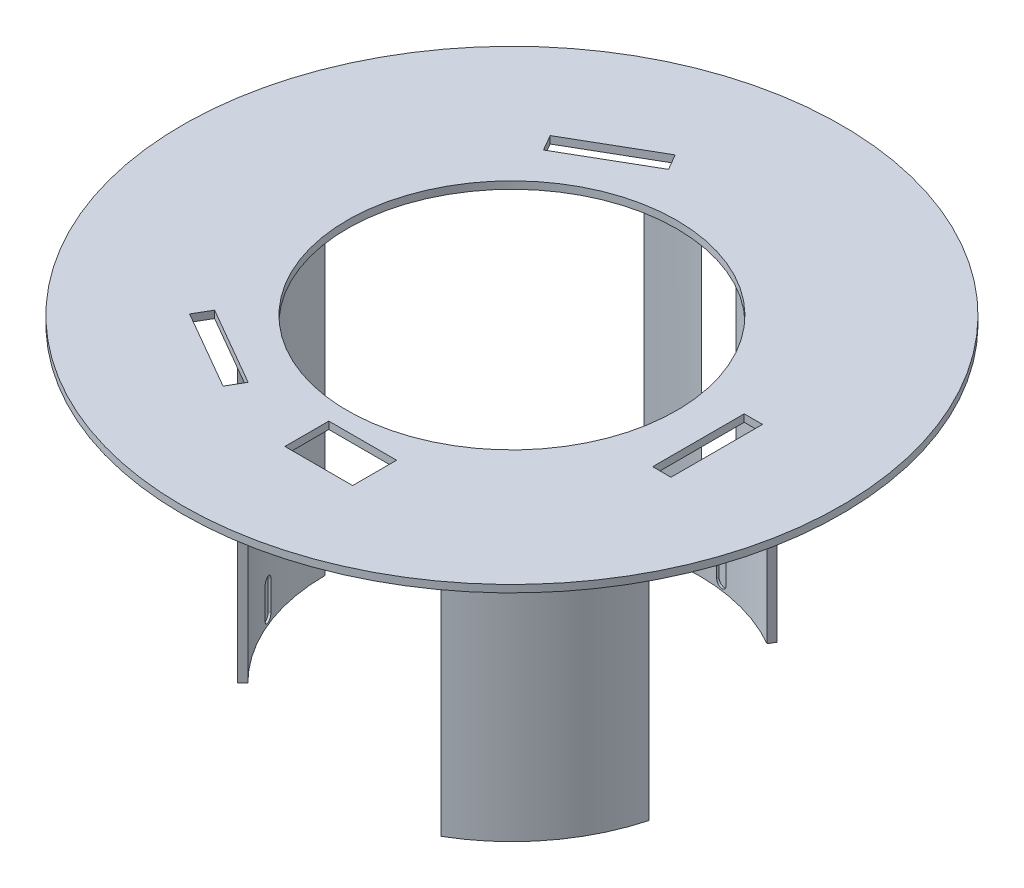
from build123d import *

# Parameters (mm, degrees)
SKETCH3_R           = 90
BOSS_EXTRUDE3_DEPTH = 2
SKETCH4_R           = 45
CUT_EXTRUDE1_DEPTH  = 2
BOSS_EXTRUDE4_DEPTH = 85
BOSS_EXTRUDE5_DEPTH = 85
CUT_EXTRUDE9_DEPTH  = 10
CIRPATTERN4_COUNT   = 3
CUT_EXTRUDE5_DEPTH  = 60
SKETCH15_W          = 5
SKETCH15_H          = 25
CUT_EXTRUDE10_DEPTH = 88.0000001
CIRPATTERN5_COUNT   = 3
SKETCH16_R          = 46
CUT_EXTRUDE11_DEPTH = 85
BOSS_EXTRUDE6_DEPTH = 2
SKETCH18_W          = 18.5
SKETCH18_H          = 12
CUT_EXTRUDE12_DEPTH = 2


with BuildPart() as part:
    # Sketch3 → Boss-Extrude3 (new body)
    with BuildSketch(Plane(origin=(0, 0, 0), x_dir=(1, 0, 0), z_dir=(0, 1, 0))):
        Circle(SKETCH3_R)
    extrude(amount=BOSS_EXTRUDE3_DEPTH)

    # Sketch4 → Cut-Extrude1 (cut)
    with BuildSketch(Plane.XZ):
        Circle(SKETCH4_R)
    extrude(amount=-CUT_EXTRUDE1_DEPTH, mode=Mode.SUBTRACT)

    # Sketch6 → Boss-Extrude4 (add)
    with BuildSketch(Plane.XZ):
        with BuildLine():
            Line((-46, 0), (-45, 0))
            ThreePointArc((-45, 0), (-41.574578963, 17.220754456), (-31.819805153, 31.819805153))
            Line((-31.819805153, 31.819805153), (-32.526911935, 32.526911935))
            ThreePointArc((-32.526911935, 32.526911935), (-42.498458496, 17.603437889), (-46, 0))
        make_face()
    boss_extrude4 = extrude(amount=BOSS_EXTRUDE4_DEPTH)

    # Sketch6_3 → Boss-Extrude5 (add)
    with BuildSketch(Plane.XZ):
        with BuildLine():
            Line((-53, 0), (-51, 0))
            ThreePointArc((-51, 0), (-47.117856158, 19.516855051), (-36.062445841, 36.062445841))
            Line((-36.062445841, 36.062445841), (-37.476659403, 37.476659403))
            ThreePointArc((-37.476659403, 37.476659403), (-48.965615223, 20.282221915), (-53, 0))
        make_face()
    boss_extrude5 = extrude(amount=BOSS_EXTRUDE5_DEPTH)

    # Sketch14 → Cut-Extrude9 (cut)
    with BuildSketch(Plane(origin=(-38.409902577, 0, 15.909902577), x_dir=(-0.382683432, 0, -0.923879533), z_dir=(0.923879533, 0, -0.382683432))):
        with BuildLine():
            Line((1.5, -75), (1.5, -83))
            ThreePointArc((1.5, -83), (0, -84.5), (-1.5, -83))
            Line((-1.5, -83), (-1.5, -75))
            ThreePointArc((-1.5, -75), (0, -73.5), (1.5, -75))
        make_face()
    cut_extrude9 = extrude(amount=-CUT_EXTRUDE9_DEPTH, mode=Mode.SUBTRACT)

    # CirPattern4: Boss-Extrude4, Boss-Extrude5, Cut-Extrude9 ×3 about axis
    cirpattern4_axis = Axis((0, 0, 0), (0, 1, 0))
    for i in range(1, CIRPATTERN4_COUNT):
        add(boss_extrude4.rotate(cirpattern4_axis, i * 360 / CIRPATTERN4_COUNT))
        add(boss_extrude5.rotate(cirpattern4_axis, i * 360 / CIRPATTERN4_COUNT))
        add(cut_extrude9.rotate(cirpattern4_axis, i * 360 / CIRPATTERN4_COUNT), mode=Mode.SUBTRACT)

    # Sketch11 → Cut-Extrude5 (cut, symmetric)
    with BuildSketch(Plane.XZ):
        Polygon((-6.747570404, -52.479477871), (11.40662685, -48.919264104), (13.715954699, -60.69495962), (-4.438242555, -64.255173387), align=None)
    extrude(amount=CUT_EXTRUDE5_DEPTH, both=True, mode=Mode.SUBTRACT)

    # Sketch15 → Cut-Extrude10 (cut, through all)
    with BuildSketch(Plane(origin=(0, 2, 0), x_dir=(1, 0, 0), z_dir=(0, 1, 0))):
        with Locations((57.5, -4.067185812)):
            Rectangle(SKETCH15_W, SKETCH15_H)
    cut_extrude10 = extrude(amount=-CUT_EXTRUDE10_DEPTH, mode=Mode.SUBTRACT)

    # CirPattern5: Cut-Extrude10 ×3 about axis
    cirpattern5_axis = Axis((0, 0, 0), (0, 1, 0))
    for i in range(1, CIRPATTERN5_COUNT):
        add(cut_extrude10.rotate(cirpattern5_axis, i * 360 / CIRPATTERN5_COUNT), mode=Mode.SUBTRACT)

    # Sketch16 → Cut-Extrude11 (cut)
    with BuildSketch(Plane.XZ.offset(85)):
        Circle(SKETCH16_R)
    extrude(amount=-CUT_EXTRUDE11_DEPTH, mode=Mode.SUBTRACT)

    # Sketch17 → Boss-Extrude6 (add)
    with BuildSketch(Plane(origin=(0, 2, 0), x_dir=(1, 0, 0), z_dir=(0, 1, 0))):
        Polygon((13.715954699, 60.69495962), (-4.438242555, 64.255173387), (-6.747570404, 52.479477871), (11.40662685, 48.919264104), align=None)
    extrude(amount=-BOSS_EXTRUDE6_DEPTH)

    # Sketch18 → Cut-Extrude12 (cut)
    with BuildSketch(Plane(origin=(0, 2, 0), x_dir=(1, 0, 0), z_dir=(0, 1, 0))):
        with Locations((9.25, -56)):
            Rectangle(SKETCH18_W, SKETCH18_H)
    extrude(amount=-CUT_EXTRUDE12_DEPTH, mode=Mode.SUBTRACT)


solid = part.part
